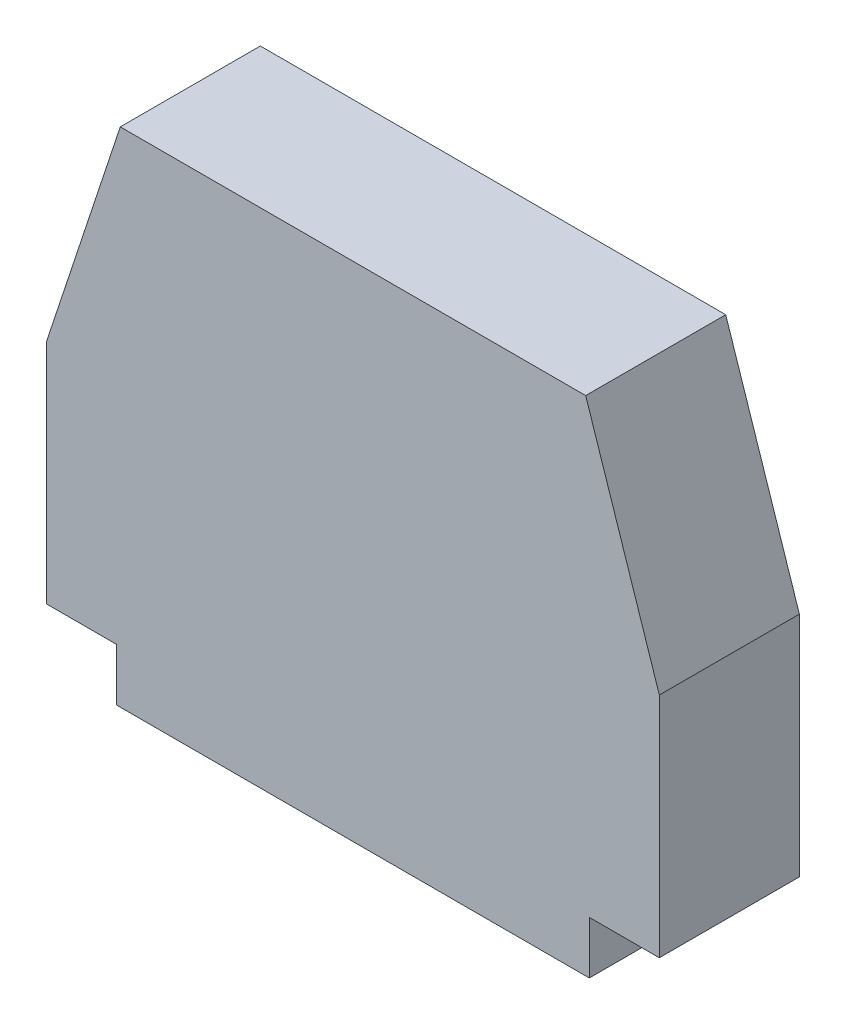
from build123d import *

# Parameters (mm, degrees)
EXTRUDE_1_DEPTH = 8


with BuildPart() as part:
    # Эскиз1 → Бобышка-Вытянуть1 (new body)
    with BuildSketch(Plane.XY):
        Polygon((-13.5, 0), (13.5, 0), (13.5, 3), (17.5, 3), (17.5, 16), (13.292429035, 28.708824613), (-13.292429035, 28.708824613), (-17.5, 16), (-17.5, 3), (-13.5, 3), align=None)
    extrude(amount=EXTRUDE_1_DEPTH)


solid = part.part
